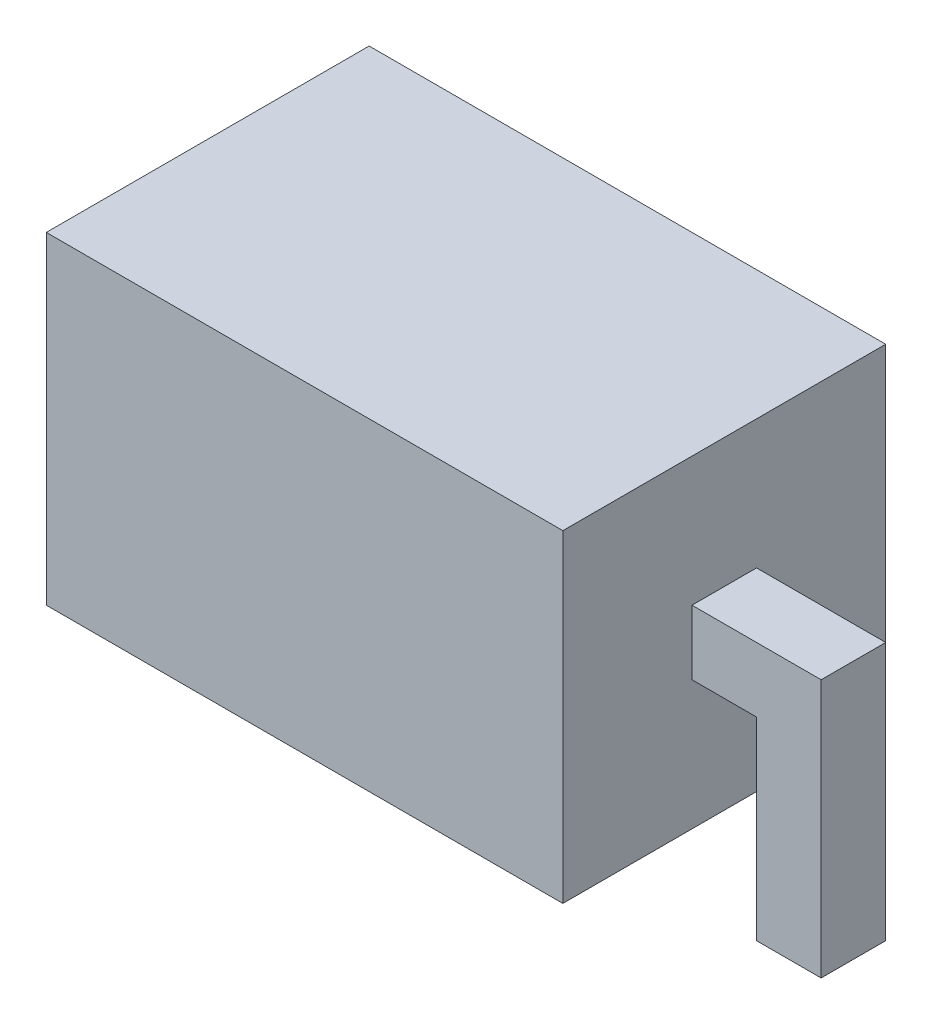
from build123d import *

# Parameters (mm, degrees)
SKETCH99_W               = 4
SKETCH99_H               = 2.5
BOSS_EXTRUDE5_DEPTH      = 2.5
BOSS_EXTRUDE6_DEPTH      = 0.25
BOSS_EXTRUDE6_DEPTH_BACK = 0.25


with BuildPart() as part:
    # Sketch99 → Boss-Extrude5 (new body)
    with BuildSketch(Plane.XY):
        Rectangle(SKETCH99_W, SKETCH99_H)
    extrude(amount=BOSS_EXTRUDE5_DEPTH)

    # Sketch100 → Boss-Extrude6 (add, two sides)
    with BuildSketch(Plane.XY.offset(1.25)) as boss_extrude6_sk:
        Polygon((2, 0.25), (2, -0.25), (2.5, -0.25), (2.5, -1.75), (3, -1.75), (3, -0.25), (3, 0.25), align=None)
        Polygon((-2.5, -0.25), (-2.5, -1.75), (-3, -1.75), (-3, 0.25), (-2, 0.25), (-2, -0.25), align=None)
    extrude(amount=BOSS_EXTRUDE6_DEPTH)
    extrude(boss_extrude6_sk.sketch, amount=-BOSS_EXTRUDE6_DEPTH_BACK)


solid = part.part
